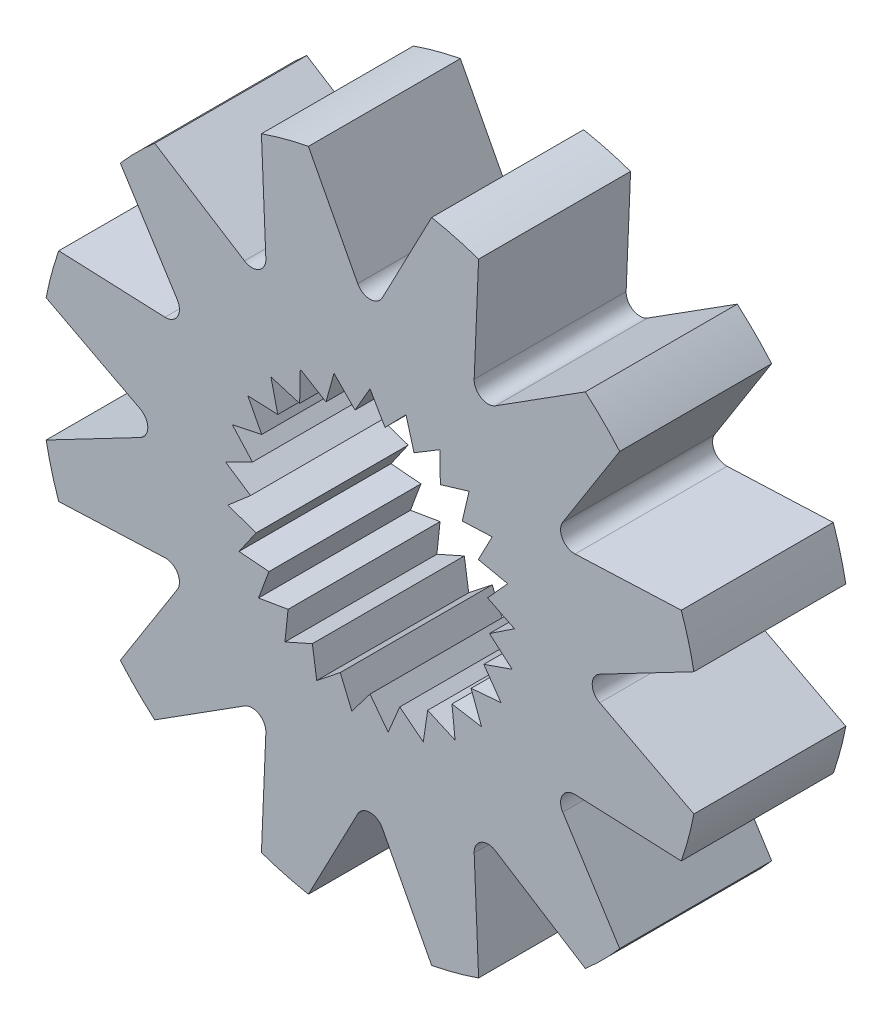
from build123d import *

# Parameters (mm, degrees)
SKETCH1_R           = 6.942600547
BOSS_EXTRUDE1_DEPTH = 3.2004
CUT_EXTRUDE1_DEPTH  = 3.2004


with BuildPart() as part:
    # Sketch1 → Boss-Extrude1 (new body)
    with BuildSketch(Plane.XY):
        Circle(SKETCH1_R)
        Polygon((0, 3.048), (-0.315924789, 2.500802214), (-0.758006776, 2.952241475), (-0.927923651, 2.343667613), (-1.468385199, 2.670982761), (-1.481617658, 2.039271757), (-2.086499579, 2.221896376), (-1.942216178, 1.606740957), (-2.573511517, 1.633200071), (-2.280778112, 1.073252713), (-2.898820262, 0.941883799), (-2.47603037, 0.472328054), (-3.041985468, 0.191385504), (-2.515704533, -0.158274714), (-2.99401154, -0.571138247), (-2.397307729, -0.778932499), (-2.757912856, -1.297775281), (-2.128279263, -1.350647091), (-2.348524364, -1.942868321), (-1.725523184, -1.837495558), (-1.791569449, -2.465883799), (-1.214346137, -2.208887422), (-1.122043637, -2.833958729), (-0.626867256, -2.441486766), (-0.382015696, -3.02396561), (0, -2.520678517), (0.382015696, -3.02396561), (0.626867256, -2.441486766), (1.122043637, -2.833958729), (1.214346137, -2.208887422), (1.791569449, -2.465883799), (1.725523184, -1.837495558), (2.348524364, -1.942868321), (2.128279263, -1.350647091), (2.757912856, -1.297775281), (2.397307729, -0.778932499), (2.99401154, -0.571138247), (2.515704533, -0.158274714), (3.041985468, 0.191385504), (2.47603037, 0.472328054), (2.898820262, 0.941883799), (2.280778112, 1.073252713), (2.573511517, 1.633200071), (1.942216178, 1.606740957), (2.086499579, 2.221896376), (1.481617658, 2.039271757), (1.468385199, 2.670982761), (0.927923651, 2.343667613), (0.758006776, 2.952241475), (0.315924789, 2.500802214), align=None, mode=Mode.SUBTRACT)
    extrude(amount=BOSS_EXTRUDE1_DEPTH)

    # Sketch2 → Cut-Extrude1 (cut)
    with BuildSketch(Plane.XY.offset(3.2004)):
        with BuildLine():
            Line((-1.297184474, 6.820338319), (-0.259835526, 4.836738163))
            ThreePointArc((-0.259835526, 4.836738163), (0, 4.679400627), (0.259835526, 4.836738163))
            Line((0.259835526, 4.836738163), (1.297184474, 6.820338319))
            ThreePointArc((1.297184474, 6.820338319), (0, 6.942600547), (-1.297184474, 6.820338319))
        make_face()
        with BuildLine():
            Line((2.643393248, 4.058820358), (4.533563867, 5.25799401))
            ThreePointArc((4.533563867, 5.25799401), (3.471300273, 6.012468442), (2.286774452, 6.555178484))
            Line((2.286774452, 6.555178484), (2.193344915, 4.318655884))
            ThreePointArc((2.193344915, 4.318655884), (2.339700314, 4.052479818), (2.643393248, 4.058820358))
        make_face()
        with BuildLine():
            Line((4.318655884, 2.193344915), (6.555178484, 2.286774452))
            ThreePointArc((6.555178484, 2.286774452), (6.012468442, 3.471300273), (5.25799401, 4.533563867))
            Line((5.25799401, 4.533563867), (4.058820358, 2.643393248))
            ThreePointArc((4.058820358, 2.643393248), (4.052479818, 2.339700314), (4.318655884, 2.193344915))
        make_face()
        with BuildLine():
            Line((4.836738163, -0.259835526), (6.820338319, -1.297184474))
            ThreePointArc((6.820338319, -1.297184474), (6.942600547, 0), (6.820338319, 1.297184474))
            Line((6.820338319, 1.297184474), (4.836738163, 0.259835526))
            ThreePointArc((4.836738163, 0.259835526), (4.679400627, 0), (4.836738163, -0.259835526))
        make_face()
        with BuildLine():
            Line((4.058820358, -2.643393248), (5.25799401, -4.533563867))
            ThreePointArc((5.25799401, -4.533563867), (6.012468442, -3.471300273), (6.555178484, -2.286774452))
            Line((6.555178484, -2.286774452), (4.318655884, -2.193344915))
            ThreePointArc((4.318655884, -2.193344915), (4.052479818, -2.339700314), (4.058820358, -2.643393248))
        make_face()
        with BuildLine():
            Line((2.193344915, -4.318655884), (2.286774452, -6.555178484))
            ThreePointArc((2.286774452, -6.555178484), (3.471300273, -6.012468442), (4.533563867, -5.25799401))
            Line((4.533563867, -5.25799401), (2.643393248, -4.058820358))
            ThreePointArc((2.643393248, -4.058820358), (2.339700314, -4.052479818), (2.193344915, -4.318655884))
        make_face()
        with BuildLine():
            Line((-0.259835526, -4.836738163), (-1.297184474, -6.820338319))
            ThreePointArc((-1.297184474, -6.820338319), (0, -6.942600547), (1.297184474, -6.820338319))
            Line((1.297184474, -6.820338319), (0.259835526, -4.836738163))
            ThreePointArc((0.259835526, -4.836738163), (0, -4.679400627), (-0.259835526, -4.836738163))
        make_face()
        with BuildLine():
            Line((-2.643393248, -4.058820358), (-4.533563867, -5.25799401))
            ThreePointArc((-4.533563867, -5.25799401), (-3.471300273, -6.012468442), (-2.286774452, -6.555178484))
            Line((-2.286774452, -6.555178484), (-2.193344915, -4.318655884))
            ThreePointArc((-2.193344915, -4.318655884), (-2.339700314, -4.052479818), (-2.643393248, -4.058820358))
        make_face()
        with BuildLine():
            Line((-4.318655884, -2.193344915), (-6.555178484, -2.286774452))
            ThreePointArc((-6.555178484, -2.286774452), (-6.012468442, -3.471300273), (-5.25799401, -4.533563867))
            Line((-5.25799401, -4.533563867), (-4.058820358, -2.643393248))
            ThreePointArc((-4.058820358, -2.643393248), (-4.052479818, -2.339700314), (-4.318655884, -2.193344915))
        make_face()
        with BuildLine():
            Line((-4.836738163, 0.259835526), (-6.820338319, 1.297184474))
            ThreePointArc((-6.820338319, 1.297184474), (-6.942600547, 0), (-6.820338319, -1.297184474))
            Line((-6.820338319, -1.297184474), (-4.836738163, -0.259835526))
            ThreePointArc((-4.836738163, -0.259835526), (-4.679400627, 0), (-4.836738163, 0.259835526))
        make_face()
        with BuildLine():
            Line((-4.058820358, 2.643393248), (-5.25799401, 4.533563867))
            ThreePointArc((-5.25799401, 4.533563867), (-6.012468442, 3.471300273), (-6.555178484, 2.286774452))
            Line((-6.555178484, 2.286774452), (-4.318655884, 2.193344915))
            ThreePointArc((-4.318655884, 2.193344915), (-4.052479818, 2.339700314), (-4.058820358, 2.643393248))
        make_face()
        with BuildLine():
            Line((-2.193344915, 4.318655884), (-2.286774452, 6.555178484))
            ThreePointArc((-2.286774452, 6.555178484), (-3.471300273, 6.012468442), (-4.533563867, 5.25799401))
            Line((-4.533563867, 5.25799401), (-2.643393248, 4.058820358))
            ThreePointArc((-2.643393248, 4.058820358), (-2.339700314, 4.052479818), (-2.193344915, 4.318655884))
        make_face()
    extrude(amount=-CUT_EXTRUDE1_DEPTH, mode=Mode.SUBTRACT)


solid = part.part
